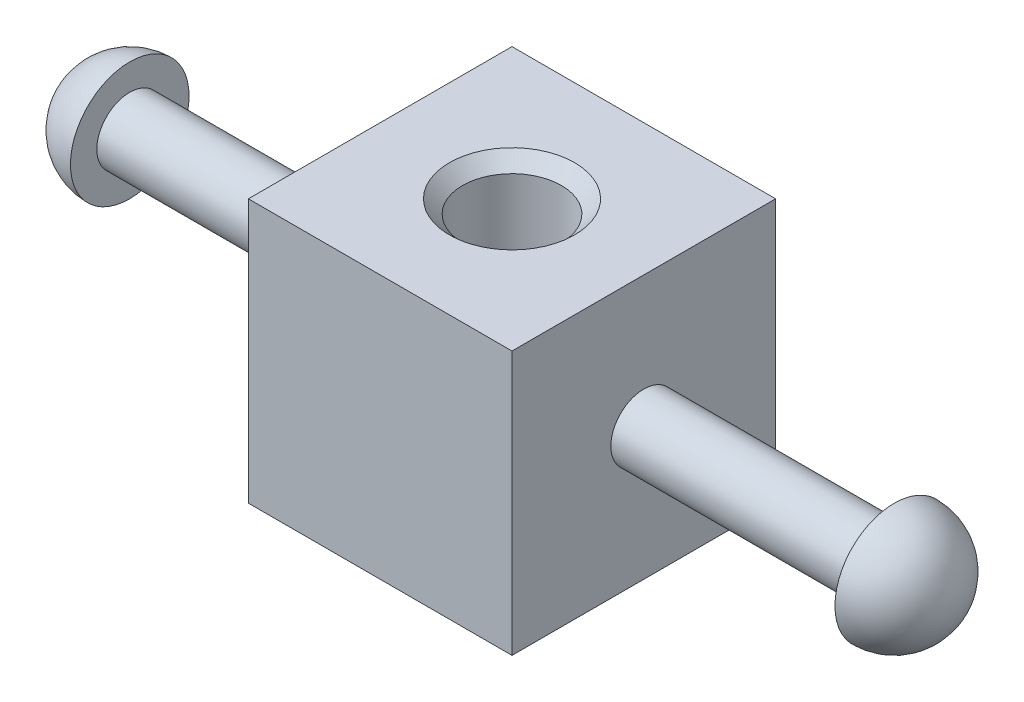
from build123d import *

# Parameters (mm, degrees)
SKETCH1_W           = 25.4
SKETCH1_H           = 25.4
SKETCH1_R           = 4.7625
BOSS_EXTRUDE1_DEPTH = 25.4
CHAMFER1_SIZE       = 1.27
SKETCH3_R           = 4.7625
CUT_EXTRUDE1_DEPTH  = 26.4


with BuildPart() as part:
    # Sketch1 → Boss-Extrude1 (new body)
    with BuildSketch(Plane(origin=(0, 0, 0), x_dir=(1, 0, 0), z_dir=(0, 1, 0))):
        Rectangle(SKETCH1_W, SKETCH1_H)
        Circle(SKETCH1_R, mode=Mode.SUBTRACT)
    extrude(amount=BOSS_EXTRUDE1_DEPTH)

    # Chamfer1
    chamfer1_edges = [part.edges().sort_by_distance(p)[0] for p in [
        (-4.7625, 0, 0),
        (-4.7625, 25.4, 0),
    ]]
    chamfer(chamfer1_edges, length=CHAMFER1_SIZE)

    # Sketch2 → Revolve1 (revolve)
    with BuildSketch(Plane(origin=(0, 12.7, 0), x_dir=(1, 0, 0), z_dir=(0, 1, 0))):
        with BuildLine():
            Line((-36.83, -3.175), (36.83, -3.175))
            Line((36.83, -3.175), (36.83, -5.715))
            ThreePointArc((36.83, -5.715), (40.871115254, -4.041115254), (42.545, 0))
            Line((42.545, 0), (-42.545, 0))
            ThreePointArc((-42.545, 0), (-40.871115254, -4.041115254), (-36.83, -5.715))
            Line((-36.83, -5.715), (-36.83, -3.175))
        make_face()
    revolve(axis=Axis((-42.545, 12.7, 0), (1, 0, 0)))

    # Sketch3 → Cut-Extrude1 (cut, through all)
    with BuildSketch(Plane(origin=(0, 25.4, 0), x_dir=(1, 0, 0), z_dir=(0, 1, 0))):
        Circle(SKETCH3_R)
    extrude(amount=-CUT_EXTRUDE1_DEPTH, mode=Mode.SUBTRACT)


solid = part.part
